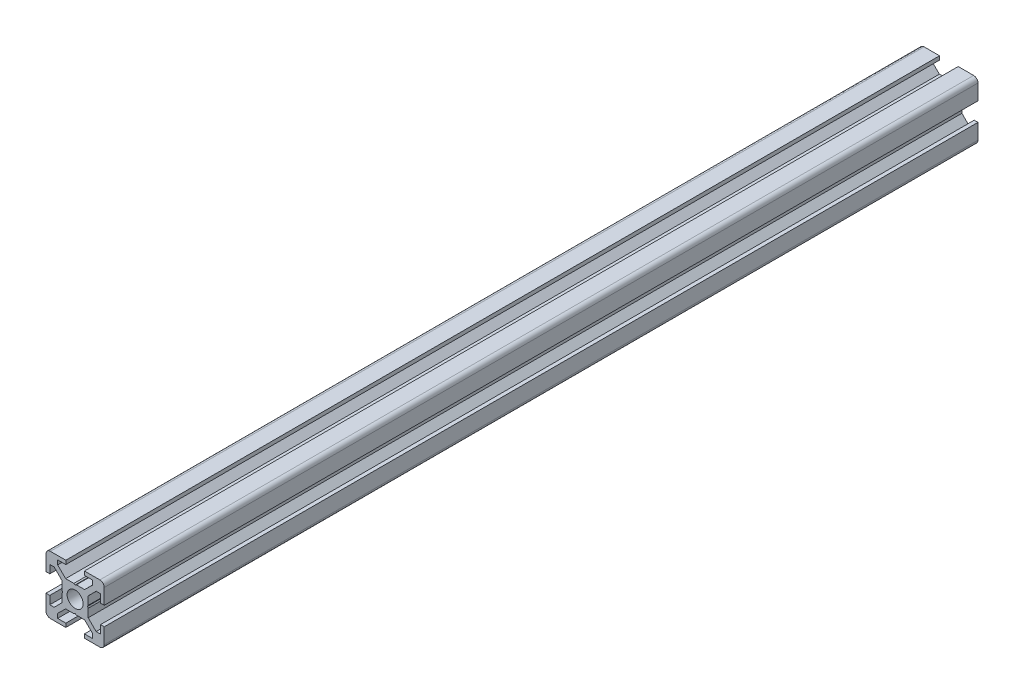
from build123d import *

# Parameters (mm, degrees)
MODEL_R             = 2.75
BOSS_EXTRUDE1_DEPTH = 300


with BuildPart() as part:
    # Model → Boss-Extrude1 (new body)
    with BuildSketch(Plane.XY):
        with BuildLine():
            Line((1.499999935, 19.99999323), (6.799999935, 19.99999323))
            Line((6.799999935, 19.99999323), (6.799999935, 18.69999323))
            Line((6.799999935, 18.69999323), (3.999999935, 18.69999323))
            Line((3.999999935, 18.69999323), (3.999999935, 17.19999323))
            Line((3.999999935, 17.19999323), (6.745762647, 14.5))
            Line((6.745762647, 14.5), (9.565216879, 14.5))
            Line((9.565216879, 14.5), (10, 14.25))
            Line((10, 14.25), (10.434782606, 14.5))
            Line((10.434782606, 14.5), (13.254244108, 14.5))
            Line((13.254244108, 14.5), (15.999999935, 17.19999323))
            Line((15.999999935, 17.19999323), (15.999999935, 18.69999323))
            Line((15.999999935, 18.69999323), (13.199999935, 18.69999323))
            Line((13.199999935, 18.69999323), (13.199999935, 19.99999323))
            Line((13.199999935, 19.99999323), (18.499999935, 19.99999323))
            ThreePointArc((18.499999935, 19.99999323), (19.560660107, 19.560653402), (19.999999935, 18.49999323))
            Line((19.999999935, 18.49999323), (19.999999935, 13.19999323))
            Line((19.999999935, 13.19999323), (18.699999935, 13.19999323))
            Line((18.699999935, 13.19999323), (18.699999935, 15.99999323))
            Line((18.699999935, 15.99999323), (17.199999935, 15.99999323))
            Line((17.199999935, 15.99999323), (14.500000065, 13.254230518))
            Line((14.500000065, 13.254230518), (14.500000065, 10.434776138))
            Line((14.500000065, 10.434776138), (14.250000065, 9.99999323))
            Line((14.250000065, 9.99999323), (14.500000065, 9.565210911))
            Line((14.500000065, 9.565210911), (14.500000065, 6.745755942))
            Line((14.500000065, 6.745755942), (17.199999935, 3.99999323))
            Line((17.199999935, 3.99999323), (18.699999935, 3.99999323))
            Line((18.699999935, 3.99999323), (18.699999935, 6.79999323))
            Line((18.699999935, 6.79999323), (19.999999935, 6.79999323))
            Line((19.999999935, 6.79999323), (19.999999935, 1.49999323))
            ThreePointArc((19.999999935, 1.49999323), (19.560660107, 0.439333058), (18.499999935, -6.77e-06))
            Line((18.499999935, -6.77e-06), (13.199999935, -6.77e-06))
            Line((13.199999935, -6.77e-06), (13.199999935, 1.29999323))
            Line((13.199999935, 1.29999323), (15.999999935, 1.29999323))
            Line((15.999999935, 1.29999323), (15.999999935, 2.798703306))
            Line((15.999999935, 2.798703306), (13.254126104, 5.49999323))
            Line((13.254126104, 5.49999323), (10.434782606, 5.49999323))
            Line((10.434782606, 5.49999323), (10, 5.74999323))
            Line((10, 5.74999323), (9.565216879, 5.49999323))
            Line((9.565216879, 5.49999323), (6.745762647, 5.49999323))
            Line((6.745762647, 5.49999323), (3.999999935, 2.79999323))
            Line((3.999999935, 2.79999323), (3.999999935, 1.29999323))
            Line((3.999999935, 1.29999323), (6.799999935, 1.29999323))
            Line((6.799999935, 1.29999323), (6.799999935, -6.77e-06))
            Line((6.799999935, -6.77e-06), (1.499999935, -6.77e-06))
            ThreePointArc((1.499999935, -6.77e-06), (0.439339764, 0.439333058), (-6.5e-08, 1.49999323))
            Line((-6.5e-08, 1.49999323), (-6.5e-08, 6.79999323))
            Line((-6.5e-08, 6.79999323), (1.299999935, 6.79999323))
            Line((1.299999935, 6.79999323), (1.299999935, 3.99999323))
            Line((1.299999935, 3.99999323), (2.799999935, 3.99999323))
            Line((2.799999935, 3.99999323), (5.499999935, 6.745755942))
            Line((5.499999935, 6.745755942), (5.499999935, 9.565210911))
            Line((5.499999935, 9.565210911), (5.749999935, 9.99999323))
            Line((5.749999935, 9.99999323), (5.499999935, 10.434776138))
            Line((5.499999935, 10.434776138), (5.499999935, 13.254230518))
            Line((5.499999935, 13.254230518), (2.799999935, 15.99999323))
            Line((2.799999935, 15.99999323), (1.299999935, 15.99999323))
            Line((1.299999935, 15.99999323), (1.299999935, 13.19999323))
            Line((1.299999935, 13.19999323), (-6.5e-08, 13.19999323))
            Line((-6.5e-08, 13.19999323), (-6.5e-08, 18.49999323))
            ThreePointArc((-6.5e-08, 18.49999323), (0.439339764, 19.560653402), (1.499999935, 19.99999323))
        make_face()
        with Locations((10, 10)):
            Circle(MODEL_R, mode=Mode.SUBTRACT)
    extrude(amount=BOSS_EXTRUDE1_DEPTH)


solid = part.part
